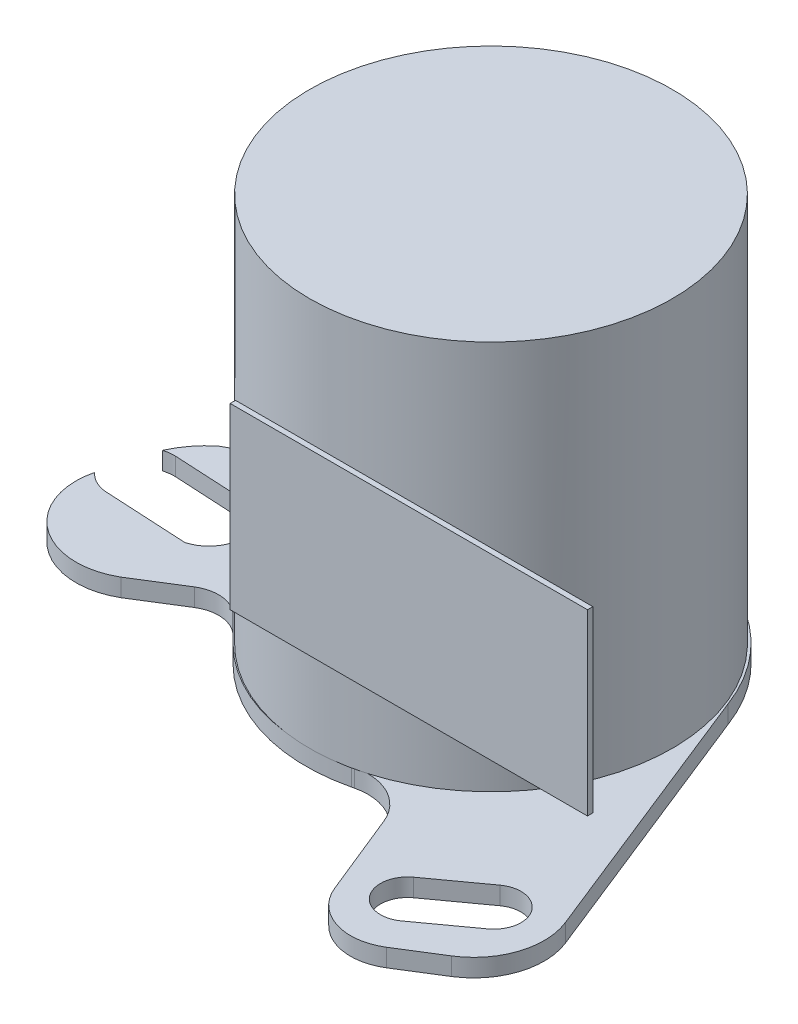
from build123d import *

# Parameters (mm, degrees)
SKETCH1_R           = 5.075
BOSS_EXTRUDE1_DEPTH = 10.9
BOSS_EXTRUDE2_DEPTH = 0.5
SKETCH3_R           = 2.5
BOSS_EXTRUDE3_DEPTH = 1
SKETCH5_R           = 0.75
BOSS_EXTRUDE4_DEPTH = 3.4
BOSS_EXTRUDE5_DEPTH = 2
SKETCH8_W           = 10
SKETCH8_H           = 5
BOSS_EXTRUDE6_DEPTH = 0.15


with BuildPart() as part:
    # Sketch1 → Boss-Extrude1 (new body)
    with BuildSketch(Plane(origin=(0, 0, 0), x_dir=(1, 0, 0), z_dir=(0, 1, 0))):
        Circle(SKETCH1_R)
    extrude(amount=BOSS_EXTRUDE1_DEPTH)

    # Sketch2 → Boss-Extrude2 (add)
    with BuildSketch(Plane.XZ):
        with BuildLine():
            Line((-8.61499055, -0.970557139), (-2.310436603, -4.508112409))
            ThreePointArc((-2.310436603, -4.508112409), (1.834277732, -4.807325107), (4.771008313, -1.867291323))
            Line((4.771008313, -1.867291323), (7.798198395, 5.717317641))
            ThreePointArc((7.798198395, 5.717317641), (7.840728806, 7.060924689), (7.011683711, 8.119117946))
            Line((7.011683711, 8.119117946), (5.893518828, 8.817225849))
            ThreePointArc((5.893518828, 8.817225849), (4.654897956, 8.969369461), (3.741442044, 8.119117946))
            Line((3.741442044, 8.119117946), (2.79817543, 5.793477847))
            ThreePointArc((2.79817543, 5.793477847), (2.106502755, 5.035708358), (1.088147054, 4.910899091))
            Line((1.088147054, 4.910899091), (1.017368736, 4.927662377))
            ThreePointArc((1.017368736, 4.927662377), (-1.462282513, 4.873270355), (-3.601116675, 3.617476885))
            Line((-3.601116675, 3.617476885), (-4.308276433, 2.910317127))
            ThreePointArc((-4.308276433, 2.910317127), (-4.893201601, 2.628113245), (-5.526672453, 2.771260597))
            Line((-5.526672453, 2.771260597), (-6.797004588, 3.564371627))
            ThreePointArc((-6.797004588, 3.564371627), (-8.964923009, 3.436038373), (-9.699583134, 1.392361734))
            ThreePointArc((-9.699583134, 1.392361734), (-9.409288056, 1.61420952), (-9.055569037, 1.70570011))
            Line((-9.055569037, 1.70570011), (-6.735755354, 1.829675082))
            ThreePointArc((-6.735755354, 1.829675082), (-6.029191067, 0.94531053), (-6.637476081, -0.009321909))
            Line((-6.637476081, -0.009321909), (-8.957289765, -0.133296881))
            ThreePointArc((-8.957289765, -0.133296881), (-9.12340547, -0.127148695), (-9.285709006, -0.091235044))
            ThreePointArc((-9.285709006, -0.091235044), (-9.00079149, -0.569371398), (-8.61499055, -0.970557139))
        make_face()
        with BuildLine():
            Line((4.576224529, 6.738378176), (5.975324732, 5.725280143))
            ThreePointArc((5.975324732, 5.725280143), (7.036113989, 5.895028611), (6.866365521, 6.955817868))
            Line((6.866365521, 6.955817868), (5.467265319, 7.968915901))
            ThreePointArc((5.467265319, 7.968915901), (4.406476062, 7.799167433), (4.576224529, 6.738378176))
        make_face(mode=Mode.SUBTRACT)
    extrude(amount=BOSS_EXTRUDE2_DEPTH)

    # Sketch3 → Boss-Extrude3 (add)
    with BuildSketch(Plane(origin=(0, -0.5, 0), x_dir=(-1, 0, 0), z_dir=(0, -1, 0))):
        Circle(SKETCH3_R)
    extrude(amount=BOSS_EXTRUDE3_DEPTH)

    # Sketch5 → Boss-Extrude4 (add)
    with BuildSketch(Plane.XZ.offset(1.5)):
        Circle(SKETCH5_R)
    extrude(amount=BOSS_EXTRUDE4_DEPTH)

    # Sketch6 → Boss-Extrude5 (add)
    with BuildSketch(Plane.XZ.offset(3.4)):
        with BuildLine():
            Line((0, 1.675), (-0.35, 1.147824028))
            ThreePointArc((-0.35, 1.147824028), (-0.370820393, 1.14126782), (-0.391518088, 1.134333984))
            Line((-0.391518088, 1.134333984), (-0.984540298, 1.355103466))
            Line((-0.984540298, 1.355103466), (-0.957829984, 0.722884307))
            ThreePointArc((-0.957829984, 0.722884307), (-0.970820393, 0.705342303), (-0.983489574, 0.687566912))
            Line((-0.983489574, 0.687566912), (-1.593019665, 0.517603466))
            Line((-1.593019665, 0.517603466), (-1.19980147, 0.021827351))
            ThreePointArc((-1.19980147, 0.021827351), (-1.2, 0), (-1.19980147, -0.021827351))
            Line((-1.19980147, -0.021827351), (-1.593019665, -0.517603466))
            Line((-1.593019665, -0.517603466), (-0.983489574, -0.687566912))
            ThreePointArc((-0.983489574, -0.687566912), (-0.970820393, -0.705342303), (-0.957829984, -0.722884307))
            Line((-0.957829984, -0.722884307), (-0.984540298, -1.355103466))
            Line((-0.984540298, -1.355103466), (-0.391518088, -1.134333984))
            ThreePointArc((-0.391518088, -1.134333984), (-0.370820393, -1.14126782), (-0.35, -1.147824028))
            Line((-0.35, -1.147824028), (0, -1.675))
            Line((0, -1.675), (0.35, -1.147824028))
            ThreePointArc((0.35, -1.147824028), (0.370820393, -1.14126782), (0.391518088, -1.134333984))
            Line((0.391518088, -1.134333984), (0.984540298, -1.355103466))
            Line((0.984540298, -1.355103466), (0.957829984, -0.722884307))
            ThreePointArc((0.957829984, -0.722884307), (0.970820393, -0.705342303), (0.983489574, -0.687566912))
            Line((0.983489574, -0.687566912), (1.593019665, -0.517603466))
            Line((1.593019665, -0.517603466), (1.19980147, -0.021827351))
            ThreePointArc((1.19980147, -0.021827351), (1.2, 0), (1.19980147, 0.021827351))
            Line((1.19980147, 0.021827351), (1.593019665, 0.517603466))
            Line((1.593019665, 0.517603466), (0.983489574, 0.687566912))
            ThreePointArc((0.983489574, 0.687566912), (0.970820393, 0.705342303), (0.957829984, 0.722884307))
            Line((0.957829984, 0.722884307), (0.984540298, 1.355103466))
            Line((0.984540298, 1.355103466), (0.391518088, 1.134333984))
            ThreePointArc((0.391518088, 1.134333984), (0.370820393, 1.14126782), (0.35, 1.147824028))
            Line((0.35, 1.147824028), (0, 1.675))
        make_face()
    extrude(amount=-BOSS_EXTRUDE5_DEPTH)


with BuildPart() as body_2:
    # Sketch8 → Boss-Extrude6 (new body)
    with BuildSketch(Plane.XY.offset(5.075)):
        with Locations((2.925, 4.9)):
            Rectangle(SKETCH8_W, SKETCH8_H)
    extrude(amount=BOSS_EXTRUDE6_DEPTH)


solid = Compound([part.part, body_2.part])
